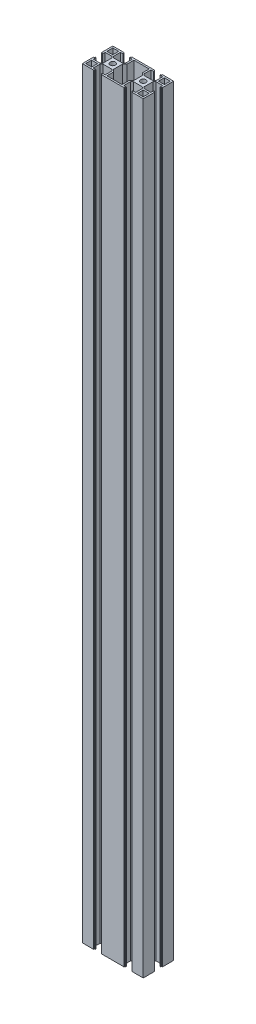
from build123d import *

# Parameters (mm, degrees)
SKETCH1_W           = 80
SKETCH1_H           = 40
BOSS_EXTRUDE1_DEPTH = 1000
SKETCH2_W           = 7.8
SKETCH2_H           = 7.8
CUT_EXTRUDE1_DEPTH  = 1001
SKETCH3_R           = 3.5
CUT_EXTRUDE2_DEPTH  = 1001


with BuildPart() as part:
    # Sketch1 → Boss-Extrude1 (new body)
    with BuildSketch(Plane(origin=(0, 0, 0), x_dir=(1, 0, 0), z_dir=(0, 1, 0))):
        Rectangle(SKETCH1_W, SKETCH1_H)
        Polygon((-27.8, -17.8), (-12.2, -17.8), (-12.2, -8.925), (-14.125, -7), (-25.875, -7), (-27.8, -8.925), align=None, mode=Mode.SUBTRACT)
        Polygon((-28.925, -7.8), (-37.8, -7.8), (-37.8, 7.8), (-28.925, 7.8), (-27, 5.875), (-27, -5.875), align=None, mode=Mode.SUBTRACT)
        Polygon((-27.8, 8.925), (-27.8, 17.8), (-12.2, 17.8), (-12.2, 8.925), (-14.125, 7), (-25.875, 7), align=None, mode=Mode.SUBTRACT)
        Polygon((27.8, 17.8), (12.2, 17.8), (12.2, 8.925), (14.125, 7), (25.875, 7), (27.8, 8.925), align=None, mode=Mode.SUBTRACT)
        Polygon((37.8, -7.8), (37.8, 7.8), (28.925, 7.8), (27, 5.875), (27, -5.875), (28.925, -7.8), align=None, mode=Mode.SUBTRACT)
        Polygon((27.8, -8.925), (27.8, -17.8), (12.2, -17.8), (12.2, -8.925), (14.125, -7), (25.875, -7), align=None, mode=Mode.SUBTRACT)
    extrude(amount=BOSS_EXTRUDE1_DEPTH)

    # Sketch2 → Cut-Extrude1 (cut, through all)
    with BuildSketch(Plane(origin=(0, 1000, 0), x_dir=(1, 0, 0), z_dir=(0, 1, 0))):
        with Locations((33.9, -13.9)):
            Rectangle(SKETCH2_W, SKETCH2_H)
        Polygon((-10, -17.8), (-10, -8.875), (-13, -5.875), (-13, 5.875), (-10, 8.875), (-10, 17.8), (10, 17.8), (10, 8.875), (13, 5.875), (13, -5.875), (10, -8.875), (10, -17.8), align=None)
        with Locations((33.9, 13.9)):
            Rectangle(SKETCH2_W, SKETCH2_H)
        with Locations((-33.9, -13.9)):
            Rectangle(SKETCH2_W, SKETCH2_H)
        with Locations((-33.9, 13.9)):
            Rectangle(SKETCH2_W, SKETCH2_H)
    extrude(amount=-CUT_EXTRUDE1_DEPTH, mode=Mode.SUBTRACT)

    # Sketch3 → Cut-Extrude2 (cut, through all)
    with BuildSketch(Plane(origin=(0, 1000, 0), x_dir=(1, 0, 0), z_dir=(0, 1, 0))):
        with Locations((-20, 0)):
            Circle(SKETCH3_R)
        with Locations((20, 0)):
            Circle(SKETCH3_R)
        Polygon((-25.1, 20), (-25.1, 18.9), (-24.1, 18.9), (-24.1, 17.8), (-15.9, 17.8), (-15.9, 18.9), (-14.9, 18.9), (-14.9, 20), align=None)
        Polygon((-37.8, 4.1), (-37.8, -4.1), (-38.9, -4.1), (-38.9, -5.1), (-40, -5.1), (-40, 5.1), (-38.9, 5.1), (-38.9, 4.1), align=None)
        Polygon((-24.1, -17.8), (-15.9, -17.8), (-15.9, -18.9), (-14.9, -18.9), (-14.9, -20), (-25.1, -20), (-25.1, -18.9), (-24.1, -18.9), align=None)
        Polygon((25.1, -20), (25.1, -18.9), (24.1, -18.9), (24.1, -17.8), (15.9, -17.8), (15.9, -18.9), (14.9, -18.9), (14.9, -20), align=None)
        Polygon((40, 5.1), (38.9, 5.1), (38.9, 4.1), (37.8, 4.1), (37.8, -4.1), (38.9, -4.1), (38.9, -5.1), (40, -5.1), align=None)
        Polygon((24.1, 17.8), (15.9, 17.8), (15.9, 18.9), (14.9, 18.9), (14.9, 20), (25.1, 20), (25.1, 18.9), (24.1, 18.9), align=None)
    extrude(amount=-CUT_EXTRUDE2_DEPTH, mode=Mode.SUBTRACT)


solid = part.part
